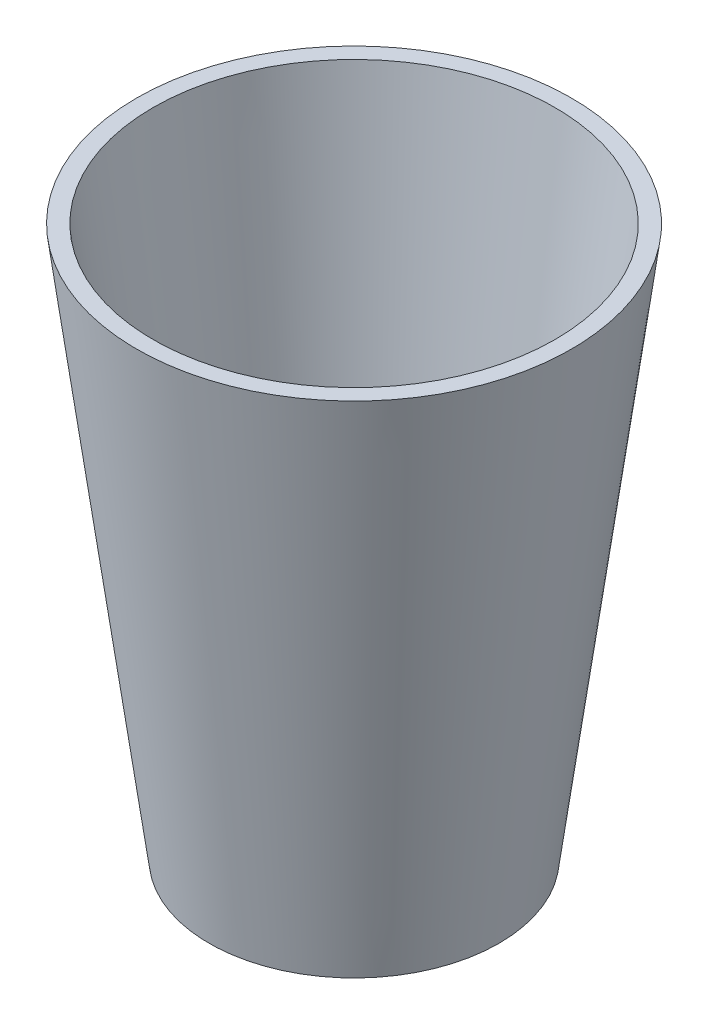
from build123d import *


with BuildPart() as part:
    # Sketch4 → Revolve2 (revolve)
    with BuildSketch(Plane.XY):
        Polygon((0, -116.947098366), (28.629276315, -116.947098366), (44.017052416, 0), (47.625, 0), (31.75, -120.65), (0, -120.65), align=None)
    revolve(axis=Axis((0, -116.947098366, 0), (0, -1, 0)))


solid = part.part
